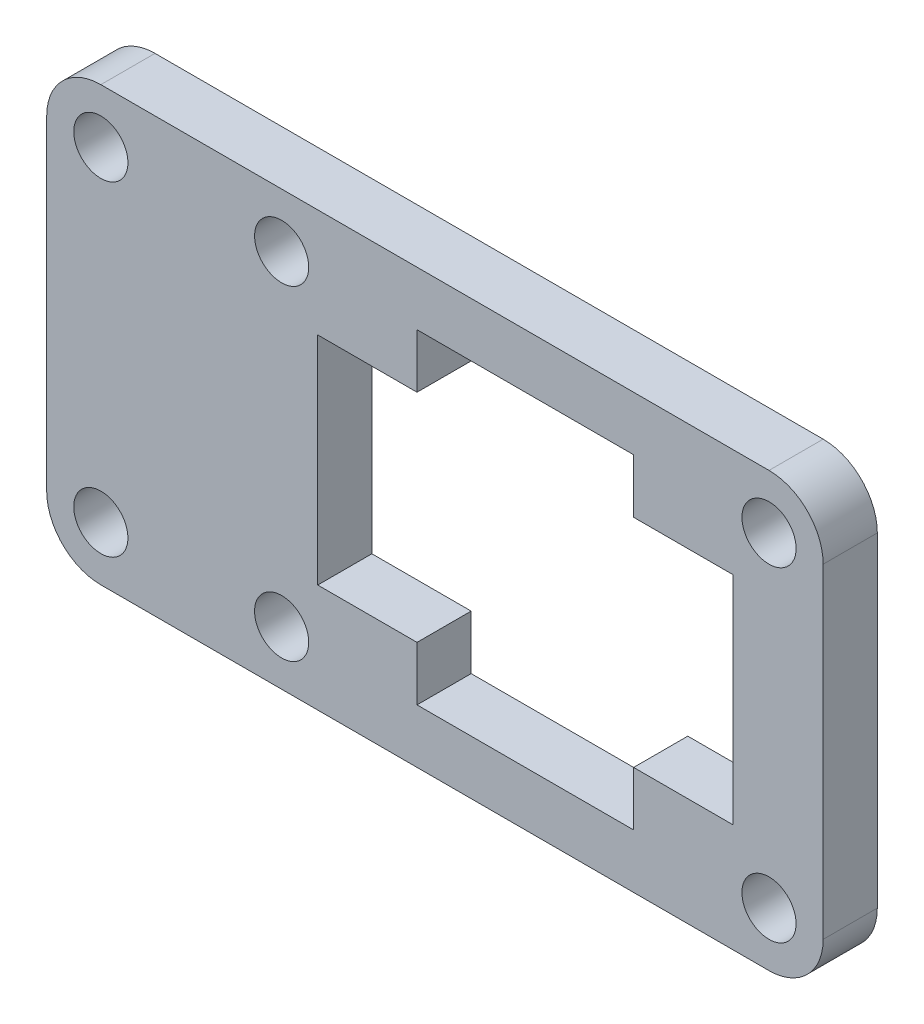
from build123d import *

# Parameters (mm, degrees)
ESQUISSE17_R        = 1.5
BOSS_EXTRU_17_DEPTH = 3


with BuildPart() as part:
    # Esquisse17 → Boss.-Extru.17 (new body)
    with BuildSketch(Plane.XY):
        with BuildLine():
            Line((26.73219077, -35.312471899), (63.748376396, -35.312471899))
            ThreePointArc((63.748376396, -35.312471899), (65.869696739, -36.191151555), (66.748376396, -38.312471899))
            Line((66.748376396, -38.312471899), (66.748376396, -56.312471899))
            ThreePointArc((66.748376396, -56.312471899), (65.869696739, -58.433792242), (63.748376396, -59.312471899))
            Line((63.748376396, -59.312471899), (26.73219077, -59.312471899))
            ThreePointArc((26.73219077, -59.312471899), (24.610870426, -58.433792242), (23.73219077, -56.312471899))
            Line((23.73219077, -56.312471899), (23.73219077, -38.312471899))
            ThreePointArc((23.73219077, -38.312471899), (24.610870426, -36.191151555), (26.73219077, -35.312471899))
        make_face()
        with Locations((26.73219077, -38.312471899)):
            Circle(ESQUISSE17_R, mode=Mode.SUBTRACT)
        with Locations((63.748376396, -38.312471899)):
            Circle(ESQUISSE17_R, mode=Mode.SUBTRACT)
        with Locations((63.748376396, -56.312471899)):
            Circle(ESQUISSE17_R, mode=Mode.SUBTRACT)
        with Locations((26.73219077, -56.312471899)):
            Circle(ESQUISSE17_R, mode=Mode.SUBTRACT)
        with Locations((36.748376396, -38.312471899)):
            Circle(ESQUISSE17_R, mode=Mode.SUBTRACT)
        with Locations((36.748376396, -56.312471899)):
            Circle(ESQUISSE17_R, mode=Mode.SUBTRACT)
        Polygon((44.248376396, -41.312471899), (44.248376396, -38.312471899), (56.248376396, -38.312471899), (56.248376396, -41.312471899), (61.748376396, -41.312471899), (61.748376396, -53.312471899), (56.248376396, -53.312471899), (56.248376396, -56.312471899), (44.248376396, -56.312471899), (44.248376396, -53.312471899), (38.748376396, -53.312471899), (38.748376396, -41.312471899), align=None, mode=Mode.SUBTRACT)
    extrude(amount=BOSS_EXTRU_17_DEPTH)


solid = part.part
